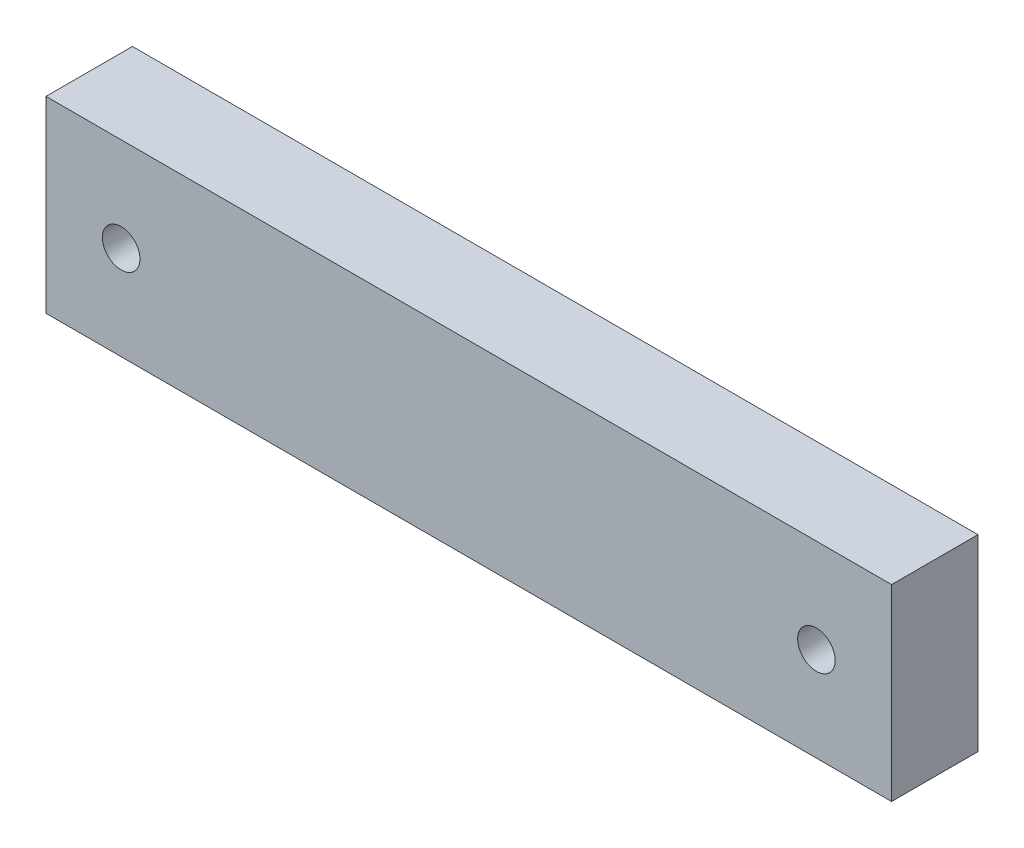
from build123d import *

# Parameters (mm, degrees)
SKETCH1_W           = 225
SKETCH1_H           = 50
SKETCH1_R           = 5
BOSS_EXTRUDE1_DEPTH = 23


with BuildPart() as part:
    # Sketch1 → Boss-Extrude1 (new body)
    with BuildSketch(Plane.XY):
        Rectangle(SKETCH1_W, SKETCH1_H)
        with Locations((92.5, 0)):
            Circle(SKETCH1_R, mode=Mode.SUBTRACT)
        with Locations((-92.5, 0)):
            Circle(SKETCH1_R, mode=Mode.SUBTRACT)
    extrude(amount=BOSS_EXTRUDE1_DEPTH)


solid = part.part
